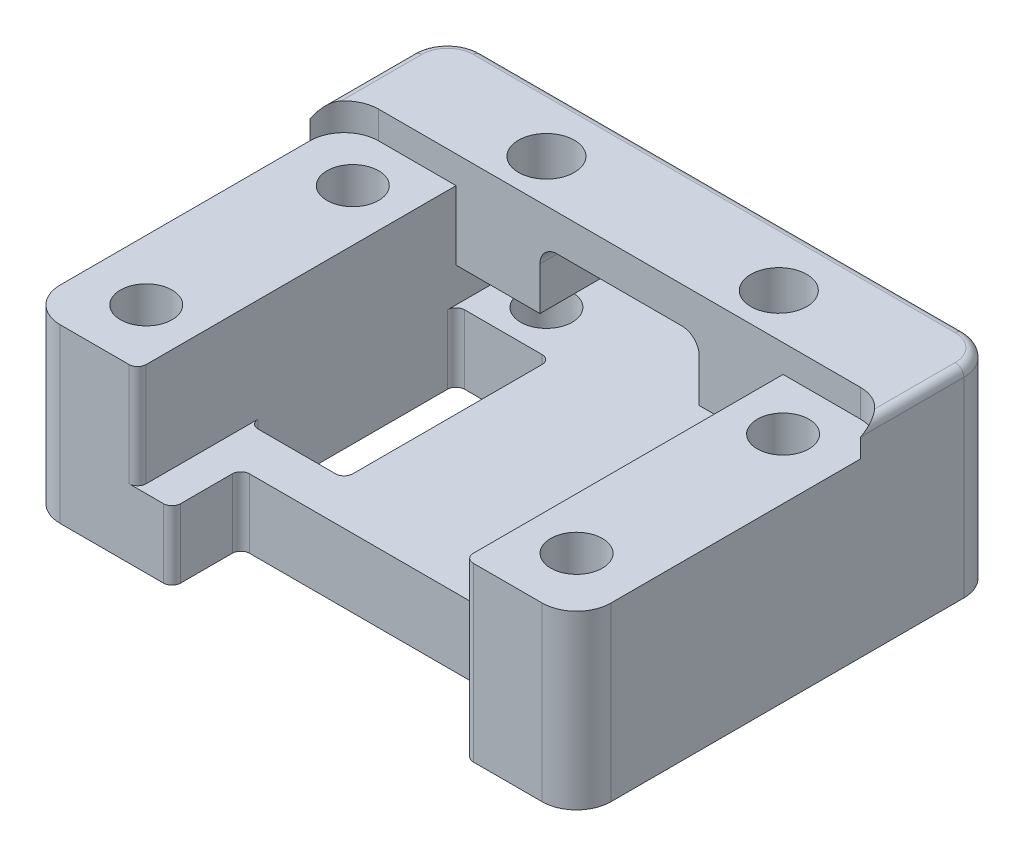
from build123d import *

# Parameters (mm, degrees)
SKETCH1_W               = 32
SKETCH1_H               = 24.5
BOSS_EXTRUDE1_DEPTH     = 10
SKETCH2_W               = 19
SKETCH2_H               = 24.5
CUT_EXTRUDE1_DEPTH      = 6
BOSS_EXTRUDE2_START     = -4
SKETCH12_W              = 32
SKETCH12_H              = 6
BOSS_EXTRUDE2_DEPTH     = 5.6
SKETCH13_W              = 9.25
SKETCH13_H              = 3.5
CUT_EXTRUDE7_DEPTH      = 25.5
SKETCH9_R               = 1.5
CUT_EXTRUDE5_DEPTH      = 8.6
CUT_EXTRUDE5_DEPTH_BACK = 5
SKETCH3_R               = 1.5
CUT_EXTRUDE2_DEPTH      = 4
SKETCH4_R               = 1.5
CUT_EXTRUDE3_DEPTH      = 7
SKETCH6_W               = 5.5
SKETCH6_H               = 12
SKETCH6_W_2             = 17
SKETCH6_H_2             = 4
CUT_EXTRUDE4_DEPTH      = 8.6
CUT_EXTRUDE4_DEPTH_BACK = 5
SKETCH16_W              = 2
SKETCH16_H              = 2
BOSS_EXTRUDE3_DEPTH     = 1.6
SKETCH17_R              = 2
CUT_EXTRUDE10_DEPTH     = 1.6
FILLET1_R               = 2
FILLET3_R               = 0.5
FILLET4_R               = 0.5
FILLET5_R               = 1
SKETCH14_R              = 1.625
CUT_EXTRUDE8_DEPTH      = 5.6


with BuildPart() as part:
    # Sketch1 → Boss-Extrude1 (new body)
    with BuildSketch(Plane(origin=(0, 0, 0), x_dir=(1, 0, 0), z_dir=(0, 1, 0))):
        Rectangle(SKETCH1_W, SKETCH1_H)
    extrude(amount=BOSS_EXTRUDE1_DEPTH)

    # Sketch2 → Cut-Extrude1 (cut)
    with BuildSketch(Plane(origin=(0, 10, 0), x_dir=(1, 0, 0), z_dir=(0, 1, 0))):
        Rectangle(SKETCH2_W, SKETCH2_H)
    extrude(amount=-CUT_EXTRUDE1_DEPTH, mode=Mode.SUBTRACT)

    # Sketch12 → Boss-Extrude2 (add)
    with BuildSketch(Plane(origin=(0, 10, 0), x_dir=(1, 0, 0), z_dir=(0, 1, 0)).offset(BOSS_EXTRUDE2_START)):
        with Locations((0, 9.25)):
            Rectangle(SKETCH12_W, SKETCH12_H)
    extrude(amount=BOSS_EXTRUDE2_DEPTH)

    # Sketch13 → Cut-Extrude7 (cut, through all)
    with BuildSketch(Plane(origin=(0, 0, -12.25), x_dir=(-1, 0, 0), z_dir=(0, 0, -1))):
        with Locations((0, 7.75)):
            Rectangle(SKETCH13_W, SKETCH13_H)
    extrude(amount=-CUT_EXTRUDE7_DEPTH, mode=Mode.SUBTRACT)

    # Sketch9 → Cut-Extrude5 (cut, two sides)
    with BuildSketch(Plane(origin=(0, 4, 0), x_dir=(1, 0, 0), z_dir=(0, 1, 0))) as cut_extrude5_sk:
        with Locations((-6.75, 8.75)):
            Circle(SKETCH9_R)
        with Locations((6.75, 8.75)):
            Circle(SKETCH9_R)
    extrude(amount=CUT_EXTRUDE5_DEPTH, mode=Mode.SUBTRACT)
    extrude(cut_extrude5_sk.sketch, amount=-CUT_EXTRUDE5_DEPTH_BACK, mode=Mode.SUBTRACT)

    # Sketch3 → Cut-Extrude2 (cut)
    with BuildSketch(Plane(origin=(0, 10, 0), x_dir=(1, 0, 0), z_dir=(0, 1, 0))):
        with Locations((-12.5, 3.25)):
            Circle(SKETCH3_R)
        with Locations((-12.5, -8.75)):
            Circle(SKETCH3_R)
        with Locations((12.5, -8.75)):
            Circle(SKETCH3_R)
        with Locations((12.5, 3.25)):
            Circle(SKETCH3_R)
        with Locations((-6.75, 8.75)):
            Circle(SKETCH3_R)
        with Locations((6.75, 8.75)):
            Circle(SKETCH3_R)
    extrude(amount=-CUT_EXTRUDE2_DEPTH, mode=Mode.SUBTRACT)

    # Sketch4 → Cut-Extrude3 (cut, through all)
    with BuildSketch(Plane(origin=(0, 6, 0), x_dir=(1, 0, 0), z_dir=(0, 1, 0))):
        with Locations((-12.5, 3.25)):
            Circle(SKETCH4_R)
        with Locations((-12.5, -8.75)):
            Circle(SKETCH4_R)
        with Locations((12.5, 3.25)):
            Circle(SKETCH4_R)
        with Locations((12.5, -8.75)):
            Circle(SKETCH4_R)
    extrude(amount=-CUT_EXTRUDE3_DEPTH, mode=Mode.SUBTRACT)

    # Sketch6 → Cut-Extrude4 (cut, two sides)
    with BuildSketch(Plane(origin=(0, 4, 0), x_dir=(1, 0, 0), z_dir=(0, 1, 0))) as cut_extrude4_sk:
        with Locations((-6.75, 0.25)):
            Rectangle(SKETCH6_W, SKETCH6_H)
        with Locations((1, -10.25)):
            Rectangle(SKETCH6_W_2, SKETCH6_H_2)
    extrude(amount=CUT_EXTRUDE4_DEPTH, mode=Mode.SUBTRACT)
    extrude(cut_extrude4_sk.sketch, amount=-CUT_EXTRUDE4_DEPTH_BACK, mode=Mode.SUBTRACT)

    # Sketch16 → Boss-Extrude3 (add)
    with BuildSketch(Plane(origin=(0, 10, 0), x_dir=(1, 0, 0), z_dir=(0, 1, 0))):
        with Locations((-15, 5.25)):
            Rectangle(SKETCH16_W, SKETCH16_H)
        with Locations((15, 5.25)):
            Rectangle(SKETCH16_W, SKETCH16_H)
    extrude(amount=BOSS_EXTRUDE3_DEPTH)

    # Sketch17 → Cut-Extrude10 (cut)
    with BuildSketch(Plane(origin=(0, 11.6, 0), x_dir=(1, 0, 0), z_dir=(0, 1, 0))):
        with Locations((-14, 4.25)):
            Circle(SKETCH17_R)
        with Locations((14, 4.25)):
            Circle(SKETCH17_R)
    extrude(amount=-CUT_EXTRUDE10_DEPTH, mode=Mode.SUBTRACT)

    # Fillet1
    fillet1_edges = [part.edges().sort_by_distance(p)[0] for p in [
        (16, 5, 12.25),
        (-16, 5, 12.25),
        (-16, 5.8, -12.25),
        (16, 5.8, -12.25),
    ]]
    fillet(fillet1_edges, radius=FILLET1_R)

    # Fillet3
    fillet3_edges = [part.edges().sort_by_distance(p)[0] for p in [
        (-9.5, 2, 5.75),
        (-9.5, 2, -6.25),
        (-4, 2, -6.25),
        (-4, 2, 5.75),
        (9.5, 2, 8.25),
        (-7.5, 2, 12.25),
        (-7.5, 2, 8.25),
        (9.5, 5, 12.25),
        (-9.5, 7, 12.25),
    ]]
    fillet(fillet3_edges, radius=FILLET3_R)

    # Fillet4
    fillet4_edges = [part.edges().sort_by_distance(p)[0] for p in [
        (-16, 11.6, -7.25),
        (0, 11.6, -12.25),
        (15.414213562, 11.6, -11.664213562),
        (-15.414213562, 11.6, -11.664213562),
        (16, 11.6, -7.25),
    ]]
    fillet(fillet4_edges, radius=FILLET4_R)

    # Fillet5
    fillet5_edges = [part.edges().sort_by_distance(p)[0] for p in [
        (-4.625, 9.5, -9.25),
        (4.625, 9.5, -9.25),
    ]]
    fillet(fillet5_edges, radius=FILLET5_R)

    # Sketch14 → Cut-Extrude8 (cut)
    with BuildSketch(Plane(origin=(0, 11.6, 0), x_dir=(1, 0, 0), z_dir=(0, 1, 0))):
        with Locations((6.75, 8.75)):
            Circle(SKETCH14_R)
        with Locations((-6.75, 8.75)):
            Circle(SKETCH14_R)
    extrude(amount=-CUT_EXTRUDE8_DEPTH, mode=Mode.SUBTRACT)


solid = part.part
